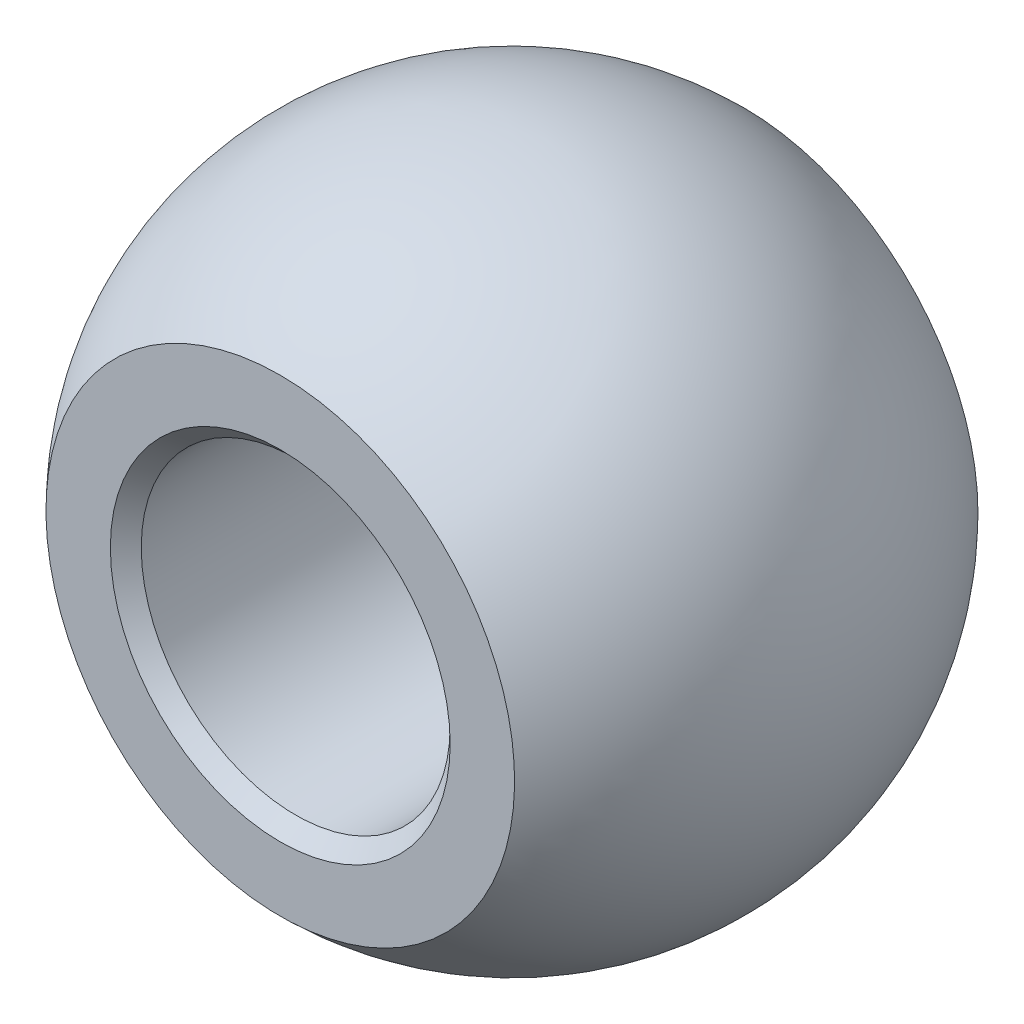
from build123d import *

# Parameters (mm, degrees)
CUT_EXTRUDE_1_DEPTH      = 12.085125168
CUT_EXTRUDE_1_DEPTH_BACK = 12.085125168
SKETCH_2_W               = 5.665320751
SKETCH_2_H               = 15.857476742
SKETCH_2_W_2             = 5.827961538
SKETCH_2_H_2             = 17.104389443
SKETCH_3_R               = 3
CUT_EXTRUDE_2_DEPTH      = 15.167921513
CHAMFER_1_SIZE           = 0.3


with BuildPart() as part:
    # Эскиз1 → Повернуть1 (revolve)
    with BuildSketch(Plane.XY):
        with BuildLine():
            Line((0, 6.4), (0, 3))
            Line((0, 3), (0, -3))
            Line((0, -3), (0, -6.4))
            ThreePointArc((0, -6.4), (-6.4, 0), (0, 6.4))
        make_face()
    revolve(axis=Axis((0, 6.4, 0), (0, -1, 0)))

    # Эскиз2 → Вырез-Вытянуть1 (cut, two sides: drawn at the far end of the back side and taken through both)
    with BuildSketch(Plane(origin=(0, 0, 0), x_dir=(0, 0, -1), z_dir=(1, 0, 0)).offset(-CUT_EXTRUDE_1_DEPTH_BACK)):
        with Locations((7.332660376, -0.020460734)):
            Rectangle(SKETCH_2_W, SKETCH_2_H)
        with Locations((-7.413980769, -0.101781127)):
            Rectangle(SKETCH_2_W_2, SKETCH_2_H_2)
    extrude(amount=CUT_EXTRUDE_1_DEPTH + CUT_EXTRUDE_1_DEPTH_BACK, mode=Mode.SUBTRACT)

    # Эскиз3 → Вырез-Вытянуть2 (cut, through all)
    with BuildSketch(Plane.XY.offset(4.5)):
        Circle(SKETCH_3_R)
    extrude(amount=-CUT_EXTRUDE_2_DEPTH, mode=Mode.SUBTRACT)

    # Фаска1
    chamfer_1_edges = [part.edges().sort_by_distance(p)[0] for p in [
        (-3, 0, -4.5),
        (-3, 0, 4.5),
    ]]
    chamfer(chamfer_1_edges, length=CHAMFER_1_SIZE)


solid = part.part
